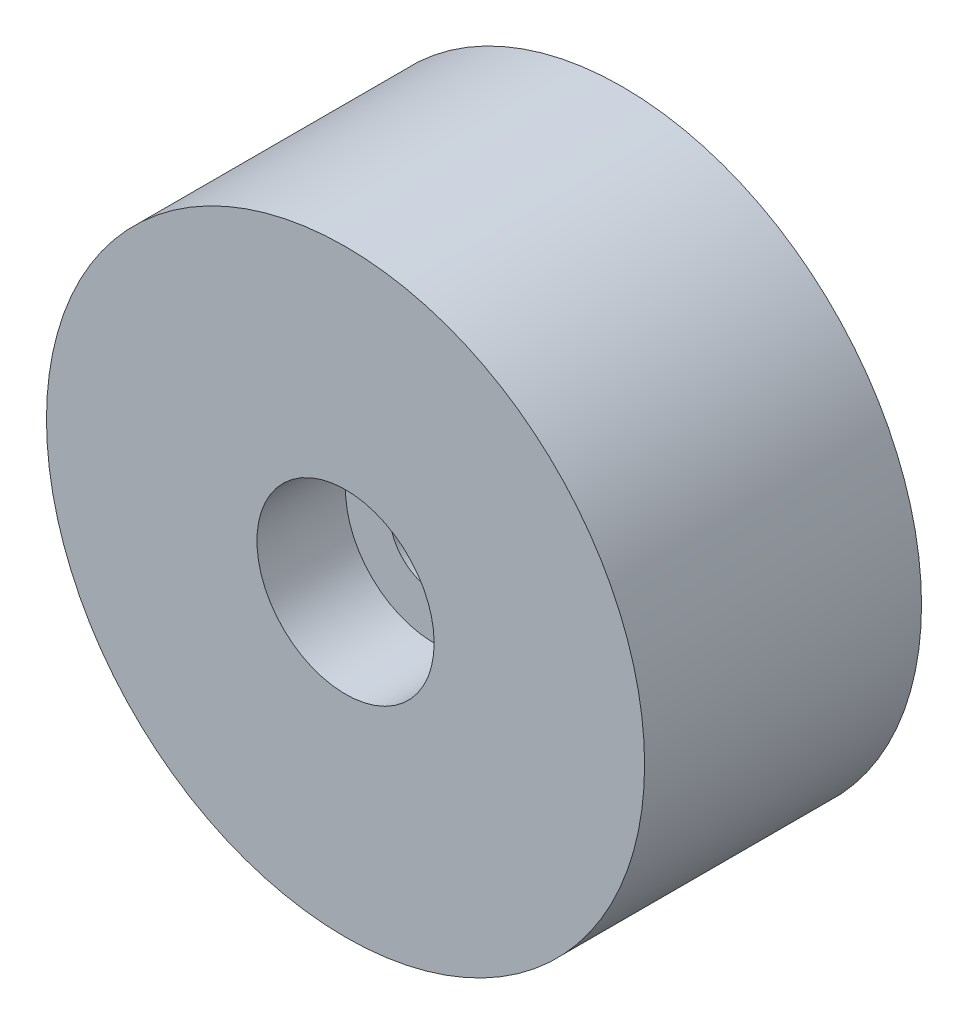
from build123d import *

# Parameters (mm, degrees)
ESQUISSE1_R             = 27
BOSS_EXTRU_1_DEPTH      = 25
ESQUISSE2_R             = 8
ENL_V_MAT_EXTRU_1_DEPTH = 8
ESQUISSE3_R             = 4
ENL_V_MAT_EXTRU_2_DEPTH = 18


with BuildPart() as part:
    # Esquisse1 → Boss.-Extru.1 (new body)
    with BuildSketch(Plane.XY):
        Circle(ESQUISSE1_R)
    extrude(amount=BOSS_EXTRU_1_DEPTH)

    # Esquisse2 → Enlèv. mat.-Extru.1 (cut)
    with BuildSketch(Plane.XY.offset(25)):
        Circle(ESQUISSE2_R)
    extrude(amount=-ENL_V_MAT_EXTRU_1_DEPTH, mode=Mode.SUBTRACT)

    # Esquisse3 → Enlèv. mat.-Extru.2 (cut, through all)
    with BuildSketch(Plane.XY.offset(17)):
        Circle(ESQUISSE3_R)
    extrude(amount=-ENL_V_MAT_EXTRU_2_DEPTH, mode=Mode.SUBTRACT)


solid = part.part
